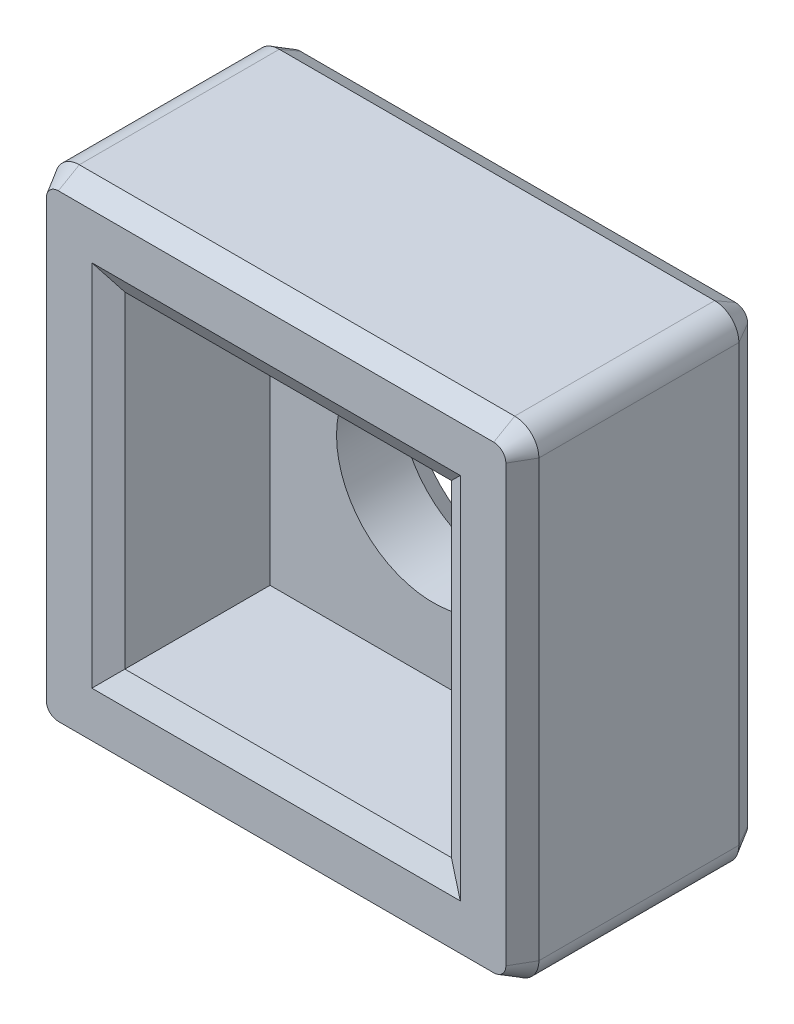
from build123d import *

# Parameters (mm, degrees)
SKETCH1_W             = 8
SKETCH1_H             = 8
BOSS_EXTRUDE1_DEPTH   = 4
FILLET1_R             = 0.4
SKETCH3_R             = 1.6
CUT_EXTRUDE1_DEPTH    = 5
SKETCH4_W             = 5.4
SKETCH4_H             = 5.4
SKETCH4_R             = 1.6
CUT_EXTRUDE2_DEPTH    = 2.6
CHAMFER1_SIZE         = 0.2
CHAMFER1_SIZE2        = 0.346410162
CHAMFER1_PART_2_SIZE  = 0.2
CHAMFER1_PART_2_SIZE2 = 0.346410162
CHAMFER1_PART_3_SIZE  = 0.2
CHAMFER1_PART_3_SIZE2 = 0.346410162
CHAMFER1_PART_4_SIZE  = 0.2
CHAMFER1_PART_4_SIZE2 = 0.346410162
CHAMFER1_PART_5_SIZE  = 0.2
CHAMFER1_PART_5_SIZE2 = 0.346410162
CHAMFER1_PART_6_SIZE  = 0.2
CHAMFER1_PART_6_SIZE2 = 0.346410162


with BuildPart() as part:
    # Sketch1 → Boss-Extrude1 (new body)
    with BuildSketch(Plane.XY):
        Rectangle(SKETCH1_W, SKETCH1_H)
    extrude(amount=BOSS_EXTRUDE1_DEPTH)

    # Fillet1
    fillet1_edges = [part.edges().sort_by_distance(p)[0] for p in [
        (-4, 4, 2),
        (4, 4, 2),
        (4, -4, 2),
        (-4, -4, 2),
    ]]
    fillet(fillet1_edges, radius=FILLET1_R)

    # Sketch3 → Cut-Extrude1 (cut, through all)
    with BuildSketch(Plane(origin=(0, 0, 0), x_dir=(-1, 0, 0), z_dir=(0, 0, -1))):
        Circle(SKETCH3_R)
    extrude(amount=-CUT_EXTRUDE1_DEPTH, mode=Mode.SUBTRACT)

    # Sketch4 → Cut-Extrude2 (cut)
    with BuildSketch(Plane.XY.offset(4)):
        Rectangle(SKETCH4_W, SKETCH4_H)
        with Locations(Location((0, 0, 0), (0, 0, 180))):  # turned: the seam where the file's is
            Circle(SKETCH4_R, mode=Mode.SUBTRACT)
    extrude(amount=-CUT_EXTRUDE2_DEPTH, mode=Mode.SUBTRACT)

    # Chamfer1
    chamfer1_edges = [part.edges().sort_by_distance(p)[0] for p in [
        (0, -4, 0),
        (-4, 0, 0),
        (0, 4, 0),
        (4, 0, 0),
        (-3.882842712, 3.882842712, 0),
        (3.882842712, 3.882842712, 0),
        (3.882842712, -3.882842712, 0),
        (-3.882842712, -3.882842712, 0),
        (1.6, 0, 0),
    ]]
    chamfer1_side = [part.faces().sort_by_distance(p)[0] for p in [
        (0, 3.886862915, 0),
    ]]
    chamfer(chamfer1_edges, length=CHAMFER1_SIZE, length2=CHAMFER1_SIZE2, reference=chamfer1_side[0])

    # Chamfer1 part 2
    chamfer1_part_2_edges = [part.edges().sort_by_distance(p)[0] for p in [
        (0, -4, 4),
        (-4, 0, 4),
        (4, 0, 4),
        (0, 4, 4),
        (-3.882842712, 3.882842712, 4),
        (3.882842712, 3.882842712, 4),
        (3.882842712, -3.882842712, 4),
        (-3.882842712, -3.882842712, 4),
    ]]
    chamfer1_part_2_side = [part.faces().sort_by_distance(p)[0] for p in [
        (0, 3.886862915, 4),
    ]]
    chamfer(chamfer1_part_2_edges, length=CHAMFER1_PART_2_SIZE, length2=CHAMFER1_PART_2_SIZE2, reference=chamfer1_part_2_side[0])

    # Chamfer1 part 3
    chamfer1_part_3_edges = [part.edges().sort_by_distance(p)[0] for p in [
        (-2.7, 0, 4),
    ]]
    chamfer1_part_3_side = [part.faces().sort_by_distance(p)[0] for p in [
        (-2.7, 0, 2.7),
    ]]
    chamfer(chamfer1_part_3_edges, length=CHAMFER1_PART_3_SIZE, length2=CHAMFER1_PART_3_SIZE2, reference=chamfer1_part_3_side[0])

    # Chamfer1 part 4
    chamfer1_part_4_edges = [part.edges().sort_by_distance(p)[0] for p in [
        (0, -2.7, 4),
    ]]
    chamfer1_part_4_side = [part.faces().sort_by_distance(p)[0] for p in [
        (0, -2.7, 2.7),
    ]]
    chamfer(chamfer1_part_4_edges, length=CHAMFER1_PART_4_SIZE, length2=CHAMFER1_PART_4_SIZE2, reference=chamfer1_part_4_side[0])

    # Chamfer1 part 5
    chamfer1_part_5_edges = [part.edges().sort_by_distance(p)[0] for p in [
        (2.7, 0, 4),
    ]]
    chamfer1_part_5_side = [part.faces().sort_by_distance(p)[0] for p in [
        (2.7, 0, 2.7),
    ]]
    chamfer(chamfer1_part_5_edges, length=CHAMFER1_PART_5_SIZE, length2=CHAMFER1_PART_5_SIZE2, reference=chamfer1_part_5_side[0])

    # Chamfer1 part 6
    chamfer1_part_6_edges = [part.edges().sort_by_distance(p)[0] for p in [
        (0, 2.7, 4),
    ]]
    chamfer1_part_6_side = [part.faces().sort_by_distance(p)[0] for p in [
        (0, 2.7, 2.7),
    ]]
    chamfer(chamfer1_part_6_edges, length=CHAMFER1_PART_6_SIZE, length2=CHAMFER1_PART_6_SIZE2, reference=chamfer1_part_6_side[0])


solid = part.part
